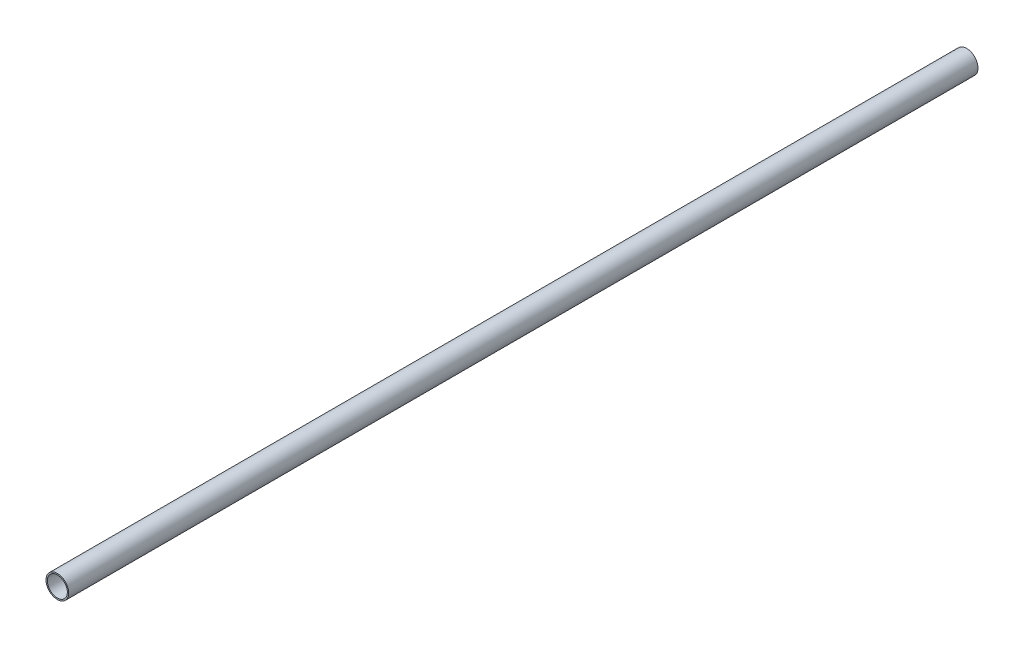
from build123d import *

# Parameters (mm, degrees)
SKETCH1_R           = 12.5
SKETCH1_R_2         = 11
BOSS_EXTRUDE1_DEPTH = 1000


with BuildPart() as part:
    # Sketch1 → Boss-Extrude1 (new body)
    with BuildSketch(Plane.XY):
        Circle(SKETCH1_R)
        Circle(SKETCH1_R_2, mode=Mode.SUBTRACT)
    extrude(amount=BOSS_EXTRUDE1_DEPTH)


solid = part.part
